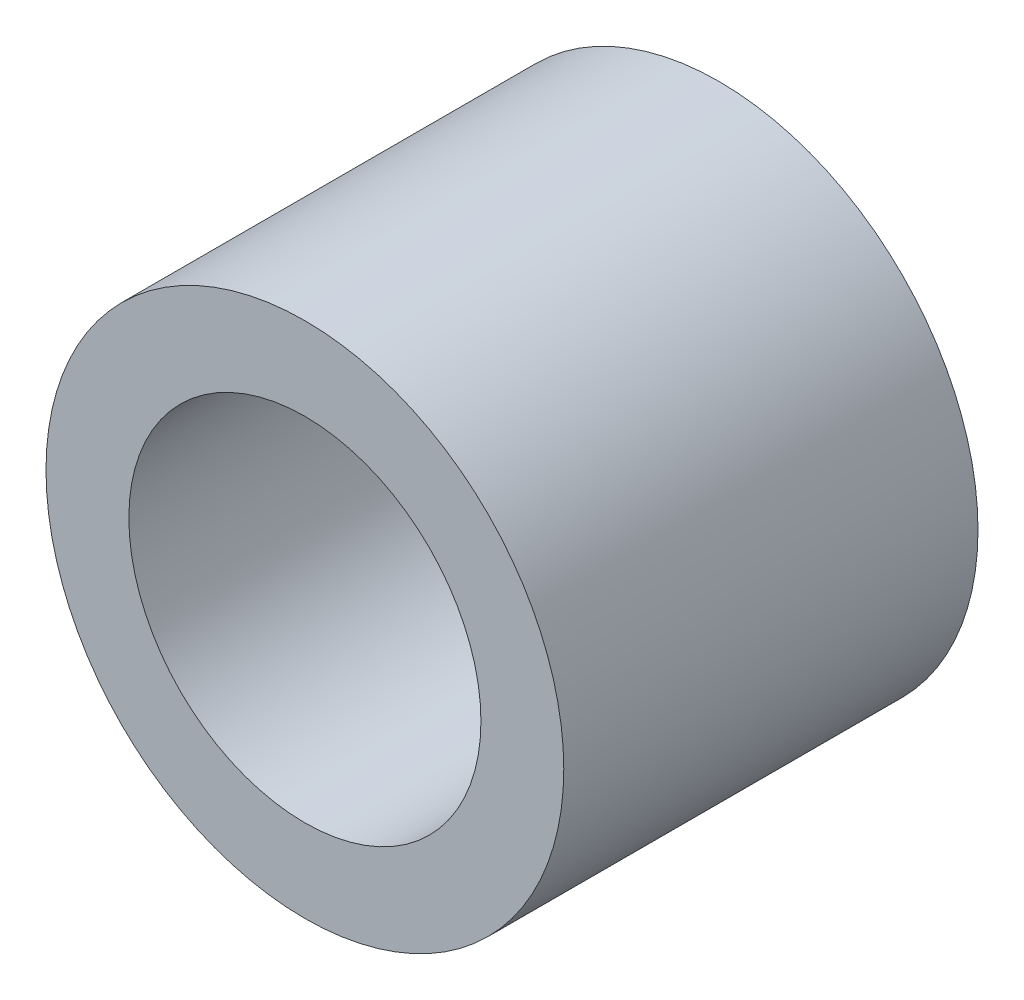
from build123d import *

# Parameters (mm, degrees)
SKETCH2_R           = 6.25
SKETCH2_R_2         = 4.25
BOSS_EXTRUDE2_DEPTH = 10


with BuildPart() as part:
    # Sketch2 → Boss-Extrude2 (new body)
    with BuildSketch(Plane.XY):
        with Locations((-44.144561606, 4.578824209)):
            Circle(SKETCH2_R)
        with Locations((-44.144561606, 4.578824209)):
            Circle(SKETCH2_R_2, mode=Mode.SUBTRACT)
    extrude(amount=BOSS_EXTRUDE2_DEPTH)


solid = part.part
